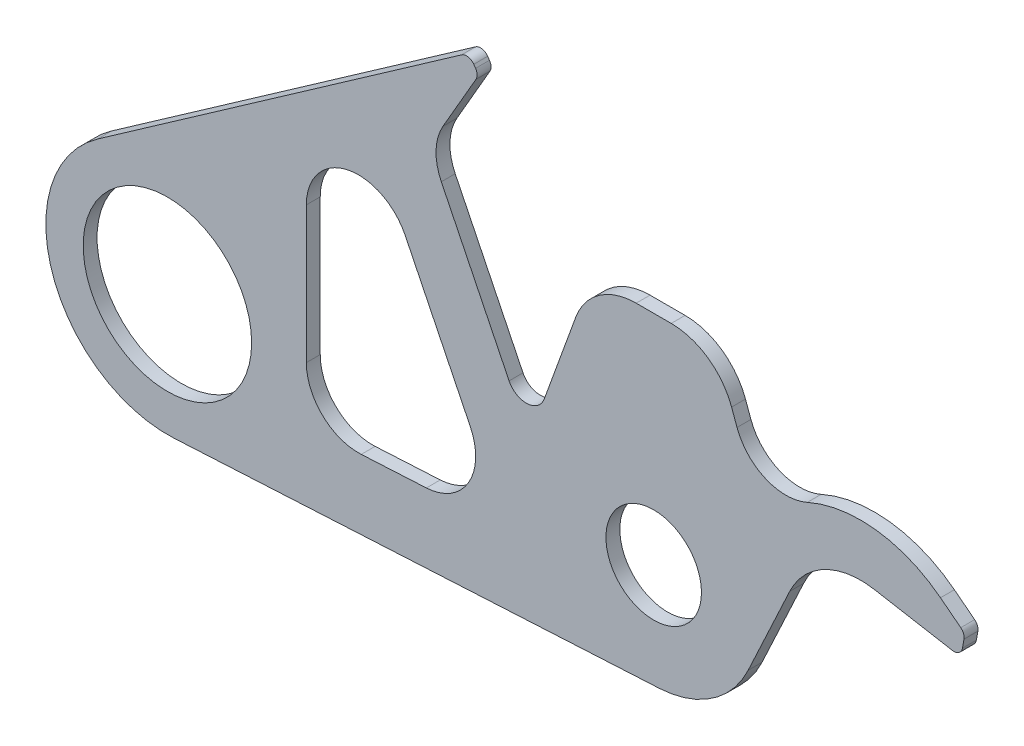
from build123d import *

# Parameters (mm, degrees)
SKETCH1_R          = 48.5
SKETCH1_R_2        = 27.5
BASE_EXTRUDE_DEPTH = 8


with BuildPart() as part:
    # Sketch1 → Base-Extrude (new body)
    with BuildSketch(Plane.XY):
        with BuildLine():
            Line((456.811048982, 62.151395165), (445.137482247, 71.222327839))
            ThreePointArc((445.137482247, 71.222327839), (408.071209791, 86.463783058), (368.448599855, 80.442214094))
            ThreePointArc((368.448599855, 80.442214094), (344.491847052, 80.189853314), (327.989727135, 97.558495432))
            Line((327.989727135, 97.558495432), (324.860948055, 106.154745303))
            ThreePointArc((324.860948055, 106.154745303), (311.314649231, 123.808625639), (290.092321086, 130.5))
            Line((290.092321086, 130.5), (269.907678914, 130.5))
            ThreePointArc((269.907678914, 130.5), (248.685350769, 123.808625639), (235.139051945, 106.154745303))
            Line((235.139051945, 106.154745303), (216.970143635, 56.236079987))
            ThreePointArc((216.970143635, 56.236079987), (207.211471113, 49.010466943), (196.743512668, 55.163760308))
            Line((196.743512668, 55.163760308), (157.717167982, 134.93418817))
            ThreePointArc((157.717167982, 134.93418817), (154.682682734, 149.146803503), (158.684274169, 163.117981024))
            Line((158.684274169, 163.117981024), (177.676526384, 196.013526811))
            ThreePointArc((177.676526384, 196.013526811), (178.341640473, 198.731623748), (177.442159587, 201.381408993))
            Line((177.442159587, 201.381408993), (176.401319854, 202.867882182))
            ThreePointArc((176.401319854, 202.867882182), (173.173800521, 204.924038765), (169.437677451, 204.095760221))
            Line((169.437677451, 204.095760221), (-40.150350545, 57.3406431))
            ThreePointArc((-40.150350545, 57.3406431), (-66.172482636, -22.829860749), (3.748206743, -69.899577583))
            Line((3.748206743, -69.899577583), (283.212748636, -54.913923642))
            ThreePointArc((283.212748636, -54.913923642), (313.581700751, -44.721920465), (334.378467222, -20.357095704))
            Line((334.378467222, -20.357095704), (358.334984681, 31.017821778))
            ThreePointArc((358.334984681, 31.017821778), (378.340147503, 51.915487493), (406.933003093, 56.316348886))
            Line((406.933003093, 56.316348886), (452.008963478, 48.368240888))
            ThreePointArc((452.008963478, 48.368240888), (455.745086548, 49.196519432), (457.801243132, 52.424038765))
            Line((457.801243132, 52.424038765), (458.667177938, 57.334999088))
            ThreePointArc((458.667177938, 57.334999088), (458.408675401, 60.001230994), (456.811048982, 62.151395165))
        make_face()
        Circle(SKETCH1_R, mode=Mode.SUBTRACT)
        with Locations((280, 5)):
            Circle(SKETCH1_R_2, mode=Mode.SUBTRACT)
        with BuildLine():
            Line((111.606374318, -24.058460629), (149.106374318, -22.04760795))
            ThreePointArc((149.106374318, -22.04760795), (173.367303133, -7.285468557), (174.447868301, 21.093146726))
            Line((174.447868301, 21.093146726), (136.947868301, 97.743703391))
            ThreePointArc((136.947868301, 97.743703391), (103.233762088, 113.786919013), (80, 84.559910536))
            Line((80, 84.559910536), (80, 5.898501192))
            ThreePointArc((80, 5.898501192), (89.362548965, -15.875235621), (111.606374318, -24.058460629))
        make_face(mode=Mode.SUBTRACT)
    extrude(amount=BASE_EXTRUDE_DEPTH)


solid = part.part
